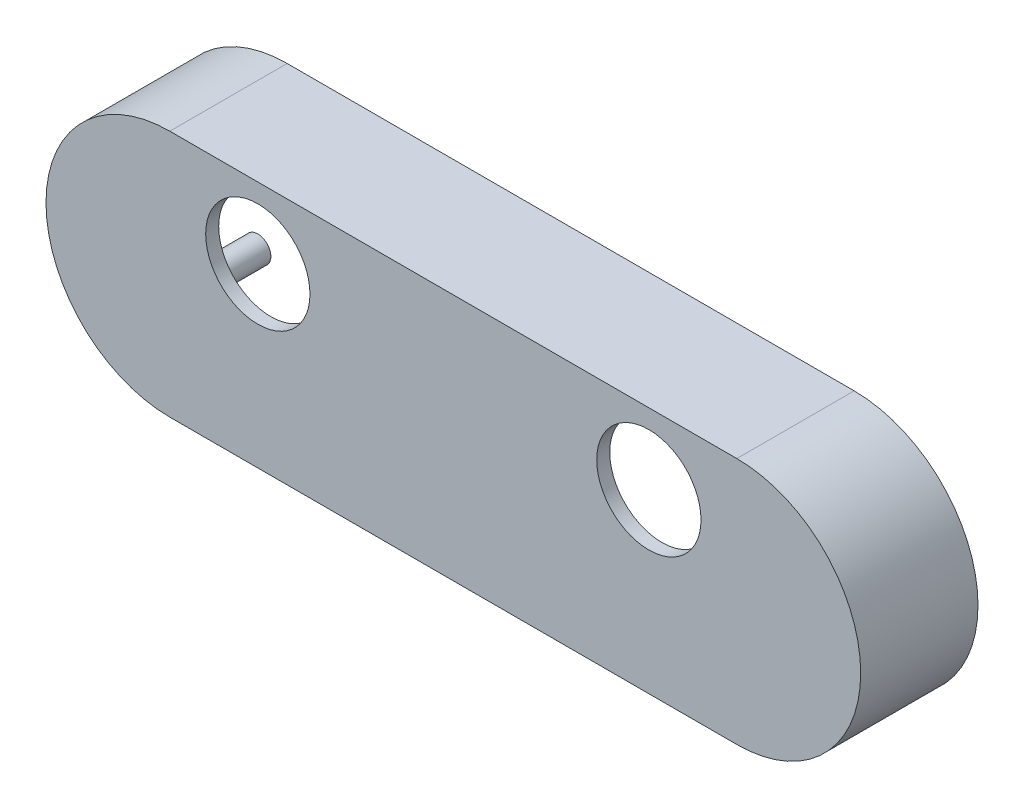
from build123d import *

# Parameters (mm, degrees)
BOSS_EXTRUDE1_DEPTH = 2
BOSS_EXTRUDE2_START = -16
BOSS_EXTRUDE2_DEPTH = 16
SKETCH2_R           = 2
SKETCH2_R_2         = 1
BOSS_EXTRUDE3_DEPTH = 8
SKETCH3_R           = 8
CUT_EXTRUDE1_DEPTH  = 8
SKETCH4_W           = 15.5
SKETCH4_H           = 6.9
SKETCH4_W_2         = 13
SKETCH4_H_2         = 4
BOSS_EXTRUDE4_DEPTH = 8
SKETCH4_2_W         = 13
SKETCH4_2_H         = 4
SKETCH4_2_R         = 4
CUT_EXTRUDE2_DEPTH  = 8


with BuildPart() as part:
    # Sketch1 → Boss-Extrude1 (new body)
    with BuildSketch(Plane.XY):
        with BuildLine():
            Line((43.5, 19), (-43.5, 19))
            ThreePointArc((-43.5, 19), (-62.5, 0), (-43.5, -19))
            Line((-43.5, -19), (43.5, -19))
            ThreePointArc((43.5, -19), (62.5, 0), (43.5, 19))
        make_face()
    extrude(amount=BOSS_EXTRUDE1_DEPTH)

    # Sketch1_3 → Boss-Extrude2 (add)
    with BuildSketch(Plane.XY.offset(BOSS_EXTRUDE2_START)):
        with BuildLine():
            Line((-43.5, 19), (43.5, 19))
            ThreePointArc((43.5, 19), (62.5, 0), (43.5, -19))
            Line((43.5, -19), (-43.5, -19))
            ThreePointArc((-43.5, -19), (-62.5, 0), (-43.5, 19))
        make_face()
        with BuildLine():
            Line((-43.5, 17), (43.5, 17))
            ThreePointArc((43.5, 17), (60.5, 0), (43.5, -17))
            Line((43.5, -17), (-43.5, -17))
            ThreePointArc((-43.5, -17), (-60.5, 0), (-43.5, 17))
        make_face(mode=Mode.SUBTRACT)
    extrude(amount=BOSS_EXTRUDE2_DEPTH)

    # Sketch2 → Boss-Extrude3 (add)
    # profile 1 of 8: a face of its own
    with BuildSketch(Plane(origin=(0, 0, 0), x_dir=(-1, 0, 0), z_dir=(0, 0, -1))):
        with Locations((-40, 15.1)):
            Circle(SKETCH2_R)
        with Locations((-40, 15.1)):
            Circle(SKETCH2_R_2, mode=Mode.SUBTRACT)
    # profile 2 of 8: a face of its own
    with BuildSketch(Plane(origin=(0, 0, 0), x_dir=(-1, 0, 0), z_dir=(0, 0, -1))):
        with Locations((-10, 15.1)):
            Circle(SKETCH2_R)
        with Locations((-10, 15.1)):
            Circle(SKETCH2_R_2, mode=Mode.SUBTRACT)
    # profile 3 of 8: a face of its own
    with BuildSketch(Plane(origin=(0, 0, 0), x_dir=(-1, 0, 0), z_dir=(0, 0, -1))):
        with Locations((-40, 0.1)):
            Circle(SKETCH2_R)
        with Locations((-40, 0.1)):
            Circle(SKETCH2_R_2, mode=Mode.SUBTRACT)
    # profile 4 of 8: a face of its own
    with BuildSketch(Plane(origin=(0, 0, 0), x_dir=(-1, 0, 0), z_dir=(0, 0, -1))):
        with Locations((-10, 0.1)):
            Circle(SKETCH2_R)
        with Locations((-10, 0.1)):
            Circle(SKETCH2_R_2, mode=Mode.SUBTRACT)
    # profile 5 of 8: a face of its own
    with BuildSketch(Plane(origin=(0, 0, 0), x_dir=(-1, 0, 0), z_dir=(0, 0, -1))):
        with Locations((10, 15.1)):
            Circle(SKETCH2_R)
        with Locations((10, 15.1)):
            Circle(SKETCH2_R_2, mode=Mode.SUBTRACT)
    # profile 6 of 8: a face of its own
    with BuildSketch(Plane(origin=(0, 0, 0), x_dir=(-1, 0, 0), z_dir=(0, 0, -1))):
        with Locations((40, 15.1)):
            Circle(SKETCH2_R)
        with Locations((40, 15.1)):
            Circle(SKETCH2_R_2, mode=Mode.SUBTRACT)
    # profile 7 of 8: a face of its own
    with BuildSketch(Plane(origin=(0, 0, 0), x_dir=(-1, 0, 0), z_dir=(0, 0, -1))):
        with Locations((10, 0.1)):
            Circle(SKETCH2_R)
        with Locations((10, 0.1)):
            Circle(SKETCH2_R_2, mode=Mode.SUBTRACT)
    # profile 8 of 8: a face of its own
    with BuildSketch(Plane(origin=(0, 0, 0), x_dir=(-1, 0, 0), z_dir=(0, 0, -1))):
        with Locations((40, 0.1)):
            Circle(SKETCH2_R)
        with Locations((40, 0.1)):
            Circle(SKETCH2_R_2, mode=Mode.SUBTRACT)
    extrude(amount=BOSS_EXTRUDE3_DEPTH)

    # Sketch3 → Cut-Extrude1 (cut)
    with BuildSketch(Plane(origin=(0, 0, 0), x_dir=(-1, 0, 0), z_dir=(0, 0, -1))):
        with Locations((30, 8.1)):
            Circle(SKETCH3_R)
        with Locations((-30, 8.1)):
            Circle(SKETCH3_R)
    extrude(amount=-CUT_EXTRUDE1_DEPTH, mode=Mode.SUBTRACT)

    # Sketch4 → Boss-Extrude4 (add)
    # profile 1 of 2: a face of its own
    with BuildSketch(Plane.XZ.offset(19)):
        with Locations((-19.25, -11.45)):
            Rectangle(SKETCH4_W, SKETCH4_H)
        with Locations((-19.25, -11.45)):
            Rectangle(SKETCH4_W_2, SKETCH4_H_2, mode=Mode.SUBTRACT)
    # profile 2 of 2: a face of its own
    with BuildSketch(Plane.XZ.offset(19)):
        with Locations((19.25, -11.45)):
            Rectangle(SKETCH4_W, SKETCH4_H)
        with Locations((19.25, -11.45)):
            Rectangle(SKETCH4_W_2, SKETCH4_H_2, mode=Mode.SUBTRACT)
    extrude(amount=BOSS_EXTRUDE4_DEPTH)

    # Sketch4_2 → Cut-Extrude2 (cut)
    with BuildSketch(Plane.XZ.offset(19)):
        with Locations((-19.25, -11.45)):
            Rectangle(SKETCH4_2_W, SKETCH4_2_H)
        with Locations((19.25, -11.45)):
            Rectangle(SKETCH4_2_W, SKETCH4_2_H)
        with Locations((0, -11.45)):
            Circle(SKETCH4_2_R)
    extrude(amount=-CUT_EXTRUDE2_DEPTH, mode=Mode.SUBTRACT)


solid = part.part
